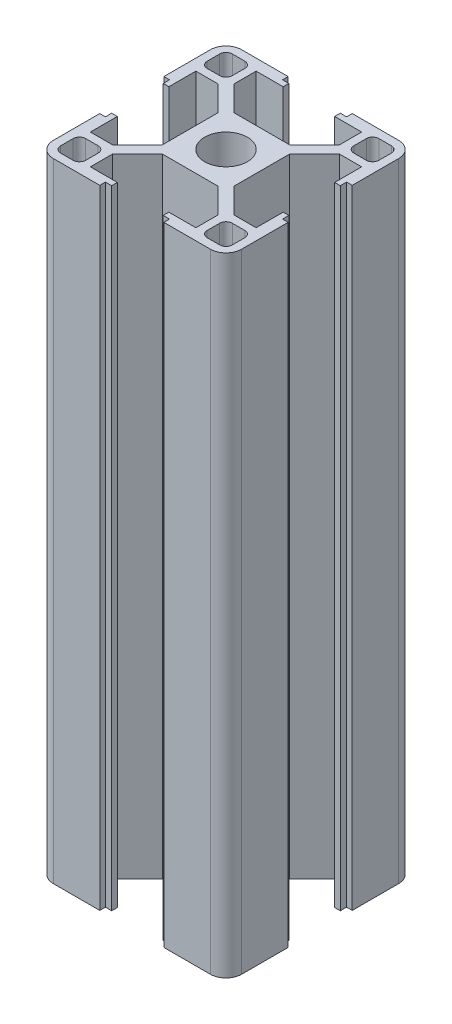
from build123d import *

# Parameters (mm, degrees)
SKETCH1_R           = 3.4
BOSS_EXTRUDE1_DEPTH = 100
CUT_EXTRUDE1_DEPTH  = 103.225241501
CIRPATTERN1_COUNT   = 4


with BuildPart() as part:
    # Sketch1 → Boss-Extrude1 (new body)
    with BuildSketch(Plane(origin=(0, 0, 0), x_dir=(1, 0, 0), z_dir=(0, 1, 0))):
        with BuildLine():
            ThreePointArc((-15, -12.5), (-14.267766953, -14.267766953), (-12.5, -15))
            Line((-12.5, -15), (12.5, -15))
            ThreePointArc((12.5, -15), (14.267766953, -14.267766953), (15, -12.5))
            Line((15, -12.5), (15, 12.5))
            ThreePointArc((15, 12.5), (14.267766953, 14.267766953), (12.5, 15))
            Line((12.5, 15), (-12.5, 15))
            ThreePointArc((-12.5, 15), (-14.267766953, 14.267766953), (-15, 12.5))
            Line((-15, 12.5), (-15, -12.5))
        make_face()
        with BuildLine():
            Line((-12.672792206, -9.672792206), (-10.672792206, -9.672792206))
            ThreePointArc((-10.672792206, -9.672792206), (-9.965685425, -9.965685425), (-9.672792206, -10.672792206))
            Line((-9.672792206, -10.672792206), (-9.672792206, -12.672792206))
            ThreePointArc((-9.672792206, -12.672792206), (-9.965685425, -13.379898987), (-10.672792206, -13.672792206))
            Line((-10.672792206, -13.672792206), (-12.672792206, -13.672792206))
            ThreePointArc((-12.672792206, -13.672792206), (-13.379898987, -13.379898987), (-13.672792206, -12.672792206))
            Line((-13.672792206, -12.672792206), (-13.672792206, -10.672792206))
            ThreePointArc((-13.672792206, -10.672792206), (-13.379898987, -9.965685425), (-12.672792206, -9.672792206))
        make_face(mode=Mode.SUBTRACT)
        Polygon((-8.4, -9.672792206), (-4.427207794, -5.7), (4.427207794, -5.7), (8.4, -9.672792206), (8.4, -13.2), (-8.4, -13.2), align=None, mode=Mode.SUBTRACT)
        with BuildLine():
            Line((9.672792206, -12.672792206), (9.672792206, -10.672792206))
            ThreePointArc((9.672792206, -10.672792206), (9.965685425, -9.965685425), (10.672792206, -9.672792206))
            Line((10.672792206, -9.672792206), (12.672792206, -9.672792206))
            ThreePointArc((12.672792206, -9.672792206), (13.379898987, -9.965685425), (13.672792206, -10.672792206))
            Line((13.672792206, -10.672792206), (13.672792206, -12.672792206))
            ThreePointArc((13.672792206, -12.672792206), (13.379898987, -13.379898987), (12.672792206, -13.672792206))
            Line((12.672792206, -13.672792206), (10.672792206, -13.672792206))
            ThreePointArc((10.672792206, -13.672792206), (9.965685425, -13.379898987), (9.672792206, -12.672792206))
        make_face(mode=Mode.SUBTRACT)
        Polygon((-5.7, 4.427207794), (-5.7, -4.427207794), (-9.672792206, -8.4), (-13.2, -8.4), (-13.2, 8.4), (-9.672792206, 8.4), align=None, mode=Mode.SUBTRACT)
        with BuildLine():
            Line((-10.672792206, 9.672792206), (-12.672792206, 9.672792206))
            ThreePointArc((-12.672792206, 9.672792206), (-13.379898987, 9.965685425), (-13.672792206, 10.672792206))
            Line((-13.672792206, 10.672792206), (-13.672792206, 12.672792206))
            ThreePointArc((-13.672792206, 12.672792206), (-13.379898987, 13.379898987), (-12.672792206, 13.672792206))
            Line((-12.672792206, 13.672792206), (-10.672792206, 13.672792206))
            ThreePointArc((-10.672792206, 13.672792206), (-9.965685425, 13.379898987), (-9.672792206, 12.672792206))
            Line((-9.672792206, 12.672792206), (-9.672792206, 10.672792206))
            ThreePointArc((-9.672792206, 10.672792206), (-9.965685425, 9.965685425), (-10.672792206, 9.672792206))
        make_face(mode=Mode.SUBTRACT)
        Circle(SKETCH1_R, mode=Mode.SUBTRACT)
        Polygon((9.672792206, 8.4), (13.2, 8.4), (13.2, -8.4), (9.672792206, -8.4), (5.7, -4.427207794), (5.7, 4.427207794), align=None, mode=Mode.SUBTRACT)
        Polygon((4.427207794, 5.7), (-4.427207794, 5.7), (-8.4, 9.672792206), (-8.4, 13.2), (8.4, 13.2), (8.4, 9.672792206), align=None, mode=Mode.SUBTRACT)
        with BuildLine():
            Line((12.672792206, 9.672792206), (10.672792206, 9.672792206))
            ThreePointArc((10.672792206, 9.672792206), (9.965685425, 9.965685425), (9.672792206, 10.672792206))
            Line((9.672792206, 10.672792206), (9.672792206, 12.672792206))
            ThreePointArc((9.672792206, 12.672792206), (9.965685425, 13.379898987), (10.672792206, 13.672792206))
            Line((10.672792206, 13.672792206), (12.672792206, 13.672792206))
            ThreePointArc((12.672792206, 13.672792206), (13.379898987, 13.379898987), (13.672792206, 12.672792206))
            Line((13.672792206, 12.672792206), (13.672792206, 10.672792206))
            ThreePointArc((13.672792206, 10.672792206), (13.379898987, 9.965685425), (12.672792206, 9.672792206))
        make_face(mode=Mode.SUBTRACT)
    extrude(amount=BOSS_EXTRUDE1_DEPTH)

    # Sketch2 → Cut-Extrude1 (cut, through all)
    with BuildSketch(Plane(origin=(0, 100, 0), x_dir=(1, 0, 0), z_dir=(0, 1, 0))):
        Polygon((-4.1, 14.1), (-4.1, 13.2), (4.1, 13.2), (4.1, 14.1), (5.1, 14.1), (5.1, 15), (-5.1, 15), (-5.1, 14.1), align=None)
    cut_extrude1 = extrude(amount=-CUT_EXTRUDE1_DEPTH, mode=Mode.SUBTRACT)

    # CirPattern1: Cut-Extrude1 ×4 about axis
    cirpattern1_axis = Axis((0, 105, 0), (0, -1, 0))
    for i in range(1, CIRPATTERN1_COUNT):
        add(cut_extrude1.rotate(cirpattern1_axis, i * 360 / CIRPATTERN1_COUNT), mode=Mode.SUBTRACT)


solid = part.part
